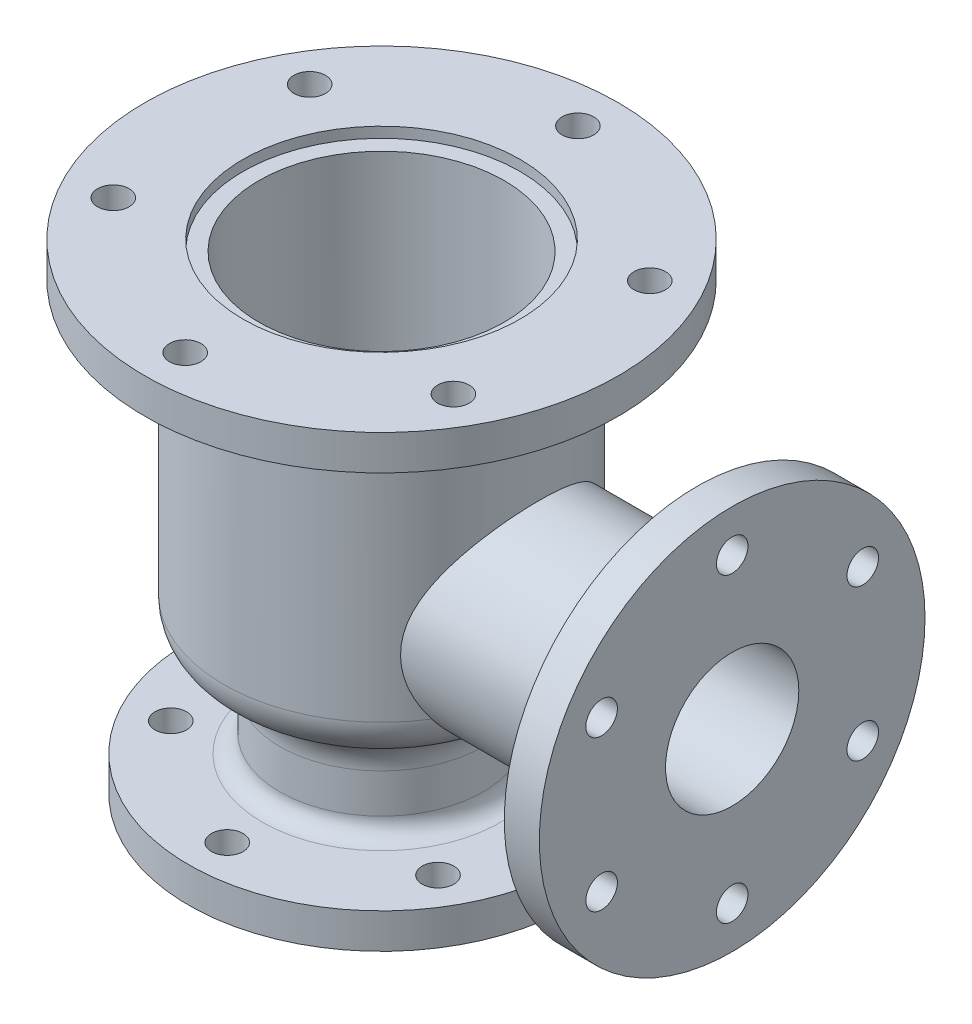
from build123d import *

# Parameters (mm, degrees)
FILLET3_R           = 25
FILLET4_R           = 25
BOSS_EXTRUDE1_REACH = 317
SKETCH2_R           = 58
SKETCH3_R           = 110
BOSS_EXTRUDE2_DEPTH = 20
CUT_EXTRUDE1_REACH  = 337
SKETCH4_R           = 38
SKETCH5_R           = 9
CUT_EXTRUDE2_DEPTH  = 20
CIRPATTERN1_COUNT   = 6
SKETCH6_R           = 9
CUT_EXTRUDE3_DEPTH  = 20
CIRPATTERN2_COUNT   = 6
SKETCH7_R           = 9
CUT_EXTRUDE4_DEPTH  = 20
CIRPATTERN3_COUNT   = 6
FILLET6_R           = 10


with BuildPart() as part:
    # Sketch1 → Revolve1 (revolve)
    with BuildSketch(Plane.XY, mode=Mode.PRIVATE) as revolve1_sk:
        with BuildLine():
            Line((38, 0), (110, 0))
            Line((110, 0), (110, 20))
            Line((110, 20), (58, 20))
            Line((58, 20), (58, 74))
            Line((58, 74), (90, 74))
            Line((90, 74), (90, 254))
            Line((90, 254), (135, 254))
            Line((135, 254), (135, 274))
            Line((135, 274), (79, 274))
            Line((79, 274), (79, 268))
            Line((79, 268), (70, 268))
            Line((70, 268), (70, 106))
            ThreePointArc((70, 106), (67.656854249, 100.343145751), (62, 98))
            Line((62, 98), (60, 98))
            Line((60, 98), (60, 88))
            Line((60, 88), (46, 88))
            Line((46, 88), (46, 34))
            Line((46, 34), (38, 34))
            Line((38, 34), (38, 0))
        make_face()
    revolve(revolve1_sk.sketch.rotate(Axis((0, 0, 0), (0, 1, 0)), 90), axis=Axis((0, 0, 0), (0, 1, 0)))  # turned: the seam where the file's is

    # Fillet3
    fillet3_edges = [part.edges().sort_by_distance(p)[0] for p in [
        (0, 74, 90),
    ]]
    fillet(fillet3_edges, radius=FILLET3_R)

    # Fillet4
    fillet4_edges = [part.edges().sort_by_distance(p)[0] for p in [
        (0, 74, 58),
    ]]
    fillet(fillet4_edges, radius=FILLET4_R)

    # Sketch2 → Boss-Extrude1 (add, up to next)
    with BuildSketch(Plane(origin=(180, 0, 0), x_dir=(0, 0, -1), z_dir=(1, 0, 0)), mode=Mode.PRIVATE) as boss_extrude1_sk1:
        with Locations((0, 132)):
            Circle(SKETCH2_R)
    boss_extrude1_tool1 = extrude(boss_extrude1_sk1.sketch, amount=-BOSS_EXTRUDE1_REACH, mode=Mode.PRIVATE) - part.part
    add(boss_extrude1_tool1.solids().sort_by_distance((180, 132, 0))[0])

    # Sketch3 → Boss-Extrude2 (add)
    with BuildSketch(Plane(origin=(180, 0, 0), x_dir=(0, 0, -1), z_dir=(1, 0, 0))):
        with Locations((0, 132)):
            Circle(SKETCH3_R)
    extrude(amount=BOSS_EXTRUDE2_DEPTH)

    # Sketch4 → Cut-Extrude1 (cut, up to next)
    with BuildSketch(Plane(origin=(200, 0, 0), x_dir=(0, 0, -1), z_dir=(1, 0, 0)), mode=Mode.PRIVATE) as cut_extrude1_sk1:
        with Locations((0, 132)):
            Circle(SKETCH4_R)
    cut_extrude1_tool1 = extrude(cut_extrude1_sk1.sketch, amount=-CUT_EXTRUDE1_REACH, mode=Mode.PRIVATE) & part.part
    add(cut_extrude1_tool1.solids().sort_by_distance((200, 132, 0))[0], mode=Mode.SUBTRACT)

    # Sketch5 → Cut-Extrude2 (cut)
    with BuildSketch(Plane(origin=(0, 274, 0), x_dir=(1, 0, 0), z_dir=(0, 1, 0))):
        with Locations(Location((0, 112, 0), (0, 0, 270))):  # turned: the seam where the file's is
            Circle(SKETCH5_R)
    cut_extrude2 = extrude(amount=-CUT_EXTRUDE2_DEPTH, mode=Mode.SUBTRACT)

    # CirPattern1: Cut-Extrude2 ×6 about axis
    cirpattern1_axis = Axis((0, 0, 0), (0, 1, 0))
    for i in range(1, CIRPATTERN1_COUNT):
        add(cut_extrude2.rotate(cirpattern1_axis, i * 360 / CIRPATTERN1_COUNT), mode=Mode.SUBTRACT)

    # Sketch6 → Cut-Extrude3 (cut)
    with BuildSketch(Plane(origin=(200, 0, 0), x_dir=(0, 0, -1), z_dir=(1, 0, 0))):
        with Locations((0, 218)):
            Circle(SKETCH6_R)
    cut_extrude3 = extrude(amount=-CUT_EXTRUDE3_DEPTH, mode=Mode.SUBTRACT)

    # CirPattern2: Cut-Extrude3 ×6 about axis
    cirpattern2_axis = Axis((0, 132, 0), (1, 0, 0))
    for i in range(1, CIRPATTERN2_COUNT):
        add(cut_extrude3.rotate(cirpattern2_axis, i * 360 / CIRPATTERN2_COUNT), mode=Mode.SUBTRACT)

    # Sketch7 → Cut-Extrude4 (cut)
    with BuildSketch(Plane(origin=(0, 20, 0), x_dir=(1, 0, 0), z_dir=(0, 1, 0))):
        with Locations(Location((0, 88, 0), (0, 0, 270))):  # turned: the seam where the file's is
            Circle(SKETCH7_R)
    cut_extrude4 = extrude(amount=-CUT_EXTRUDE4_DEPTH, mode=Mode.SUBTRACT)

    # CirPattern3: Cut-Extrude4 ×6 about axis
    cirpattern3_axis = Axis((0, 0, 0), (0, 1, 0))
    for i in range(1, CIRPATTERN3_COUNT):
        add(cut_extrude4.rotate(cirpattern3_axis, i * 360 / CIRPATTERN3_COUNT), mode=Mode.SUBTRACT)

    # Fillet6
    fillet6_edges = [part.edges().sort_by_distance(p)[0] for p in [
        (0, 20, 58),
    ]]
    fillet(fillet6_edges, radius=FILLET6_R)


solid = part.part
